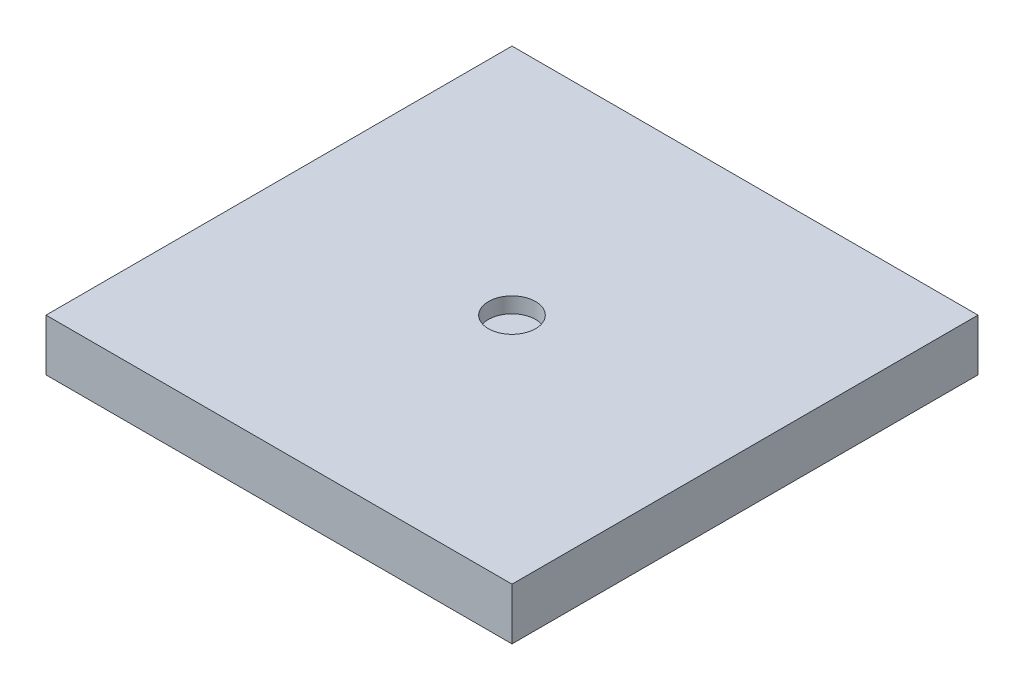
from build123d import *

# Parameters (mm, degrees)
SKETCH1_W           = 22.86
SKETCH1_H           = 22.86
BOSS_EXTRUDE1_DEPTH = 2.54
SKETCH2_R           = 1.156530307
CUT_EXTRUDE1_DEPTH  = 0.762


with BuildPart() as part:
    # Sketch1 → Boss-Extrude1 (new body)
    with BuildSketch(Plane(origin=(0, 0, 0), x_dir=(1, 0, 0), z_dir=(0, 1, 0))):
        Rectangle(SKETCH1_W, SKETCH1_H)
    extrude(amount=BOSS_EXTRUDE1_DEPTH)

    # Sketch2 → Cut-Extrude1 (cut)
    with BuildSketch(Plane(origin=(0, 2.54, 0), x_dir=(1, 0, 0), z_dir=(0, 1, 0))):
        Circle(SKETCH2_R)
    extrude(amount=-CUT_EXTRUDE1_DEPTH, mode=Mode.SUBTRACT)


solid = part.part
